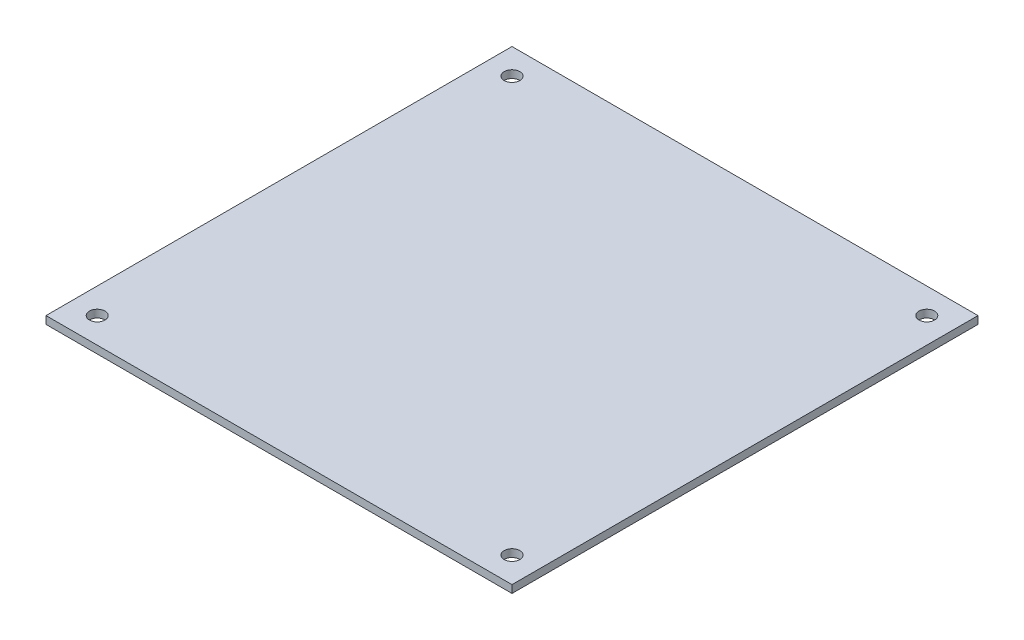
from build123d import *

# Parameters (mm, degrees)
SKETCH1_W           = 91
SKETCH1_H           = 91
SKETCH1_R           = 3.175
SKETCH1_R_2         = 1.524
BOSS_EXTRUDE1_DEPTH = 1.5


with BuildPart() as part:
    # Sketch1 → Boss-Extrude1 (new body)
    with BuildSketch(Plane(origin=(0, 0, 0), x_dir=(1, 0, 0), z_dir=(0, 1, 0))):
        Rectangle(SKETCH1_W, SKETCH1_H)
        with Locations((-40.5, -40.5)):
            Circle(SKETCH1_R, mode=Mode.SUBTRACT)
        with Locations((40.5, -40.5)):
            Circle(SKETCH1_R, mode=Mode.SUBTRACT)
        with Locations((40.5, 40.5)):
            Circle(SKETCH1_R, mode=Mode.SUBTRACT)
        with Locations((-40.5, 40.5)):
            Circle(SKETCH1_R, mode=Mode.SUBTRACT)
        with Locations((-40.5, -40.5)):
            Circle(SKETCH1_R)
        with Locations((-40.5, -40.5)):
            Circle(SKETCH1_R_2, mode=Mode.SUBTRACT)
        with Locations((-40.5, 40.5)):
            Circle(SKETCH1_R)
        with Locations((-40.5, 40.5)):
            Circle(SKETCH1_R_2, mode=Mode.SUBTRACT)
        with Locations((40.5, 40.5)):
            Circle(SKETCH1_R)
        with Locations((40.5, 40.5)):
            Circle(SKETCH1_R_2, mode=Mode.SUBTRACT)
        with Locations((40.5, -40.5)):
            Circle(SKETCH1_R)
        with Locations((40.5, -40.5)):
            Circle(SKETCH1_R_2, mode=Mode.SUBTRACT)
    extrude(amount=BOSS_EXTRUDE1_DEPTH)


solid = part.part
